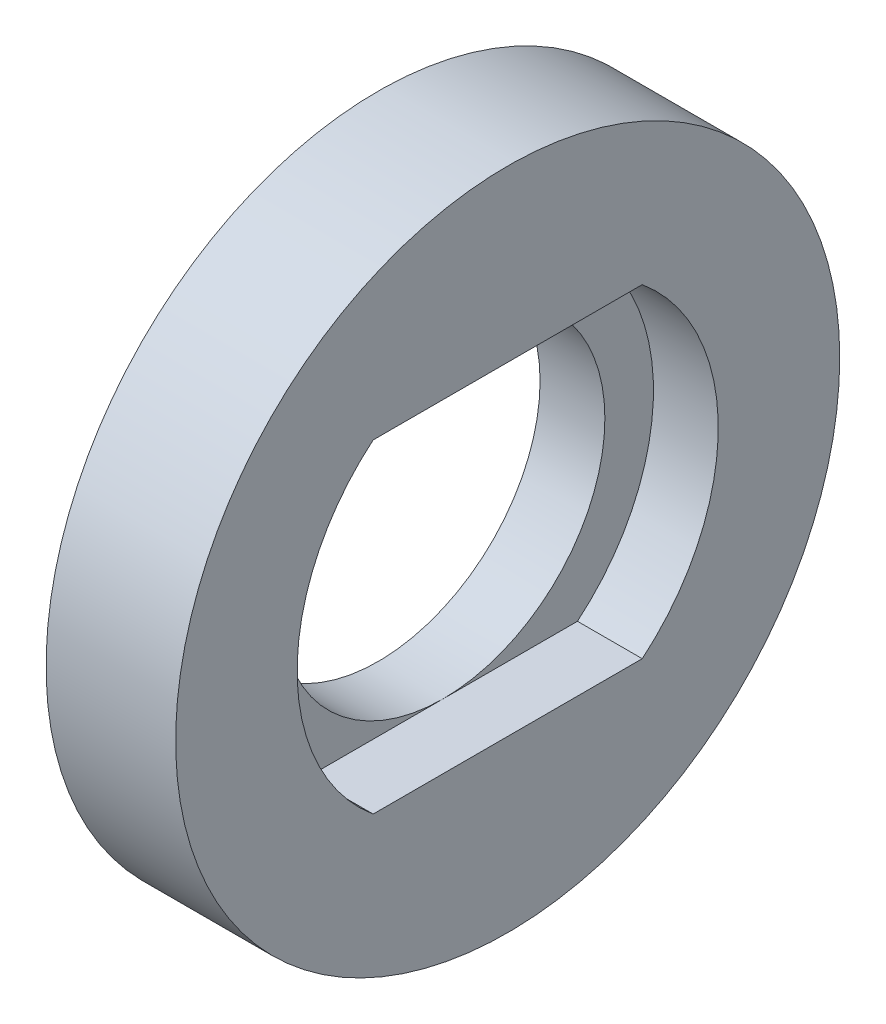
from build123d import *

# Parameters (mm, degrees)
SKETCH1_R           = 10.25
BOSS_EXTRUDE1_DEPTH = 4
SKETCH2_W           = 8.306623862
SKETCH2_H           = 10
CUT_EXTRUDE1_DEPTH  = 2
SKETCH3_R           = 5
CUT_EXTRUDE2_DEPTH  = 3


with BuildPart() as part:
    # Sketch1 → Boss-Extrude1 (new body)
    with BuildSketch(Plane(origin=(0, 0, 0), x_dir=(0, 0, -1), z_dir=(1, 0, 0))):
        Circle(SKETCH1_R)
    extrude(amount=BOSS_EXTRUDE1_DEPTH)

    # Sketch2 → Cut-Extrude1 (cut)
    with BuildSketch(Plane(origin=(4, 0, 0), x_dir=(0, 0, -1), z_dir=(1, 0, 0))):
        with BuildLine():
            ThreePointArc((-4.153311931, 5), (-6.5, 0), (-4.153311931, -5))
            Line((-4.153311931, -5), (-4.153311931, 5))
        make_face()
        Rectangle(SKETCH2_W, SKETCH2_H)
        with BuildLine():
            Line((4.153311931, 5), (4.153311931, -5))
            ThreePointArc((4.153311931, -5), (5.884153616, -2.761654617), (6.5, 0))
            ThreePointArc((6.5, 0), (5.884153616, 2.761654617), (4.153311931, 5))
        make_face()
    extrude(amount=-CUT_EXTRUDE1_DEPTH, mode=Mode.SUBTRACT)

    # Sketch3 → Cut-Extrude2 (cut, through all)
    with BuildSketch(Plane(origin=(2, 0, 0), x_dir=(0, 0, -1), z_dir=(1, 0, 0))):
        Circle(SKETCH3_R)
    extrude(amount=-CUT_EXTRUDE2_DEPTH, mode=Mode.SUBTRACT)


solid = part.part
